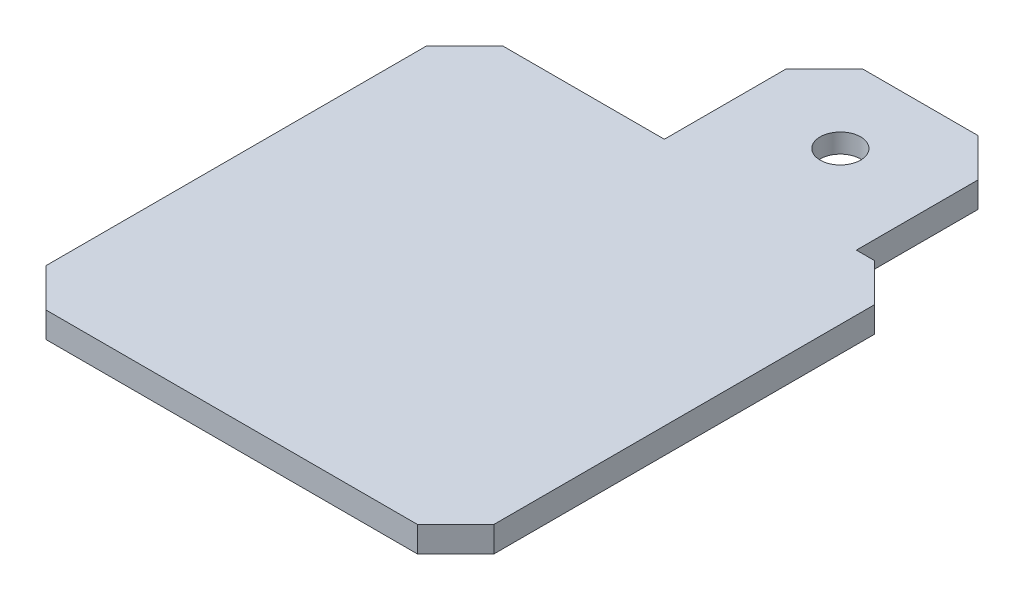
from build123d import *

# Parameters (mm, degrees)
SKETCH1_W           = 35
SKETCH1_H           = 0.7
SKETCH1_H_2         = 35
BOSS_EXTRUDE1_DEPTH = 2
CHAMFER1_SIZE       = 3
SKETCH4_R           = 2.6
SKETCH4_R_2         = 1.58
BOSS_EXTRUDE2_DEPTH = 1.5


with BuildPart() as part:
    # Sketch1 → Boss-Extrude1 (new body)
    with BuildSketch(Plane(origin=(0, 0, 0), x_dir=(1, 0, 0), z_dir=(0, 1, 0))):
        with BuildLine():
            Line((7.5, 17.5), (13.1, 17.5))
            Line((13.1, 17.5), (13.1, 30))
            Line((13.1, 30), (7.5, 30))
            Line((7.5, 30), (7.5, 25.524823935))
            ThreePointArc((7.5, 25.524823935), (8.018677324, 24.703939201), (8.2, 23.75))
            ThreePointArc((8.2, 23.75), (8.018677324, 22.796060799), (7.5, 21.975176065))
            Line((7.5, 21.975176065), (7.5, 17.5))
        make_face()
        with BuildLine():
            Line((-1.9, 30), (-1.9, 17.5))
            Line((-1.9, 17.5), (7.5, 17.5))
            Line((7.5, 17.5), (7.5, 21.975176065))
            ThreePointArc((7.5, 21.975176065), (3, 23.75), (7.5, 25.524823935))
            Line((7.5, 25.524823935), (7.5, 30))
            Line((7.5, 30), (-1.9, 30))
        make_face()
        with Locations((0, -17.85)):
            Rectangle(SKETCH1_W, SKETCH1_H)
        Rectangle(SKETCH1_W, SKETCH1_H_2)
    extrude(amount=BOSS_EXTRUDE1_DEPTH)

    # Chamfer1
    chamfer1_edges = [part.edges().sort_by_distance(p)[0] for p in [
        (-1.9, 1, -30),
        (13.1, 1, -30),
        (17.5, 1, -17.5),
        (17.5, 1, 18.2),
        (-17.5, 1, 18.2),
        (-17.5, 1, -17.5),
    ]]
    chamfer(chamfer1_edges, length=CHAMFER1_SIZE)

    # Sketch4 → Boss-Extrude2 (add)
    with BuildSketch(Plane(origin=(0, 2, 0), x_dir=(1, 0, 0), z_dir=(0, 1, 0))):
        with Locations((5.6, 23.75)):
            Circle(SKETCH4_R)
        with Locations((5.6, 23.75)):
            Circle(SKETCH4_R_2, mode=Mode.SUBTRACT)
    extrude(amount=-BOSS_EXTRUDE2_DEPTH)


solid = part.part
